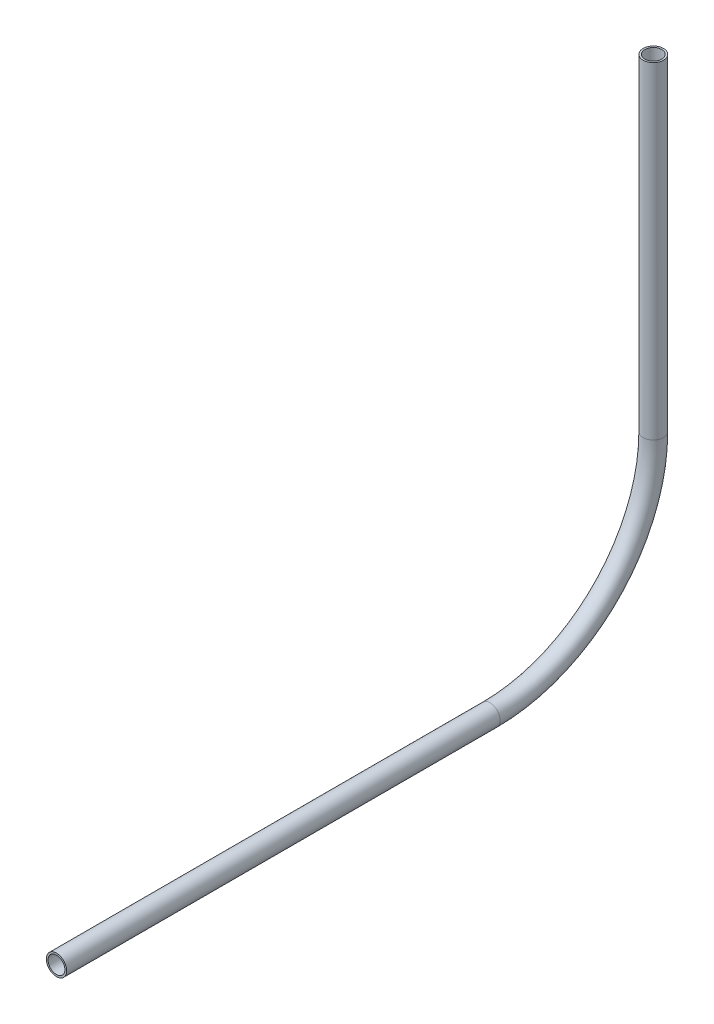
from build123d import *

# Parameters (mm, degrees)
SKETCH11_R                = 3.175
SKETCH11_R_2              = 2.6162
PIPE_0_5_SCH_40_1_DEPTH   = 134.891141117
SKETCH11_ON_SEGMENT_2_R   = 3.175
SKETCH11_ON_SEGMENT_2_R_2 = 2.6162
PIPE_0_5_SCH_40_1_2_ANGLE = 90
SKETCH11_ON_SEGMENT_3_R   = 3.175
SKETCH11_ON_SEGMENT_3_R_2 = 2.6162
PIPE_0_5_SCH_40_1_3_DEPTH = 101.698598989


with BuildPart() as part:
    # Sketch11 → Pipe 0.5 SCH 40(1) (new body)
    with BuildSketch(Plane(origin=(0, 599.960019272, 303.164595711), x_dir=(0, 1, 0), z_dir=(0, 0, -1))):
        Circle(SKETCH11_R)
        Circle(SKETCH11_R_2, mode=Mode.SUBTRACT)
    extrude(amount=PIPE_0_5_SCH_40_1_DEPTH)


with BuildPart() as body_2:
    # Sketch11 on segment 2 (carried to the start of arc 2) → Pipe 0.5 SCH 40_1 2 (revolve)
    with BuildSketch(Plane(origin=(0, 599.960019272, 168.273454594), x_dir=(0, 1, 0), z_dir=(0, 0, -1))):
        Circle(SKETCH11_ON_SEGMENT_2_R)
        Circle(SKETCH11_ON_SEGMENT_2_R_2, mode=Mode.SUBTRACT)
    revolve(axis=Axis((0, 650.760019272, 168.273454594), (1, 0, 0)), revolution_arc=PIPE_0_5_SCH_40_1_2_ANGLE)


with BuildPart() as body_3:
    # Sketch11 on segment 3 (carried to segment 3) → Pipe 0.5 SCH 40_1 3 (new body)
    with BuildSketch(Plane(origin=(0, 650.760019272, 117.473454594), x_dir=(0, 0, 1), z_dir=(0, 1, 0))):
        Circle(SKETCH11_ON_SEGMENT_3_R)
        Circle(SKETCH11_ON_SEGMENT_3_R_2, mode=Mode.SUBTRACT)
    extrude(amount=PIPE_0_5_SCH_40_1_3_DEPTH)


solid = Compound([part.part, body_2.part, body_3.part])
